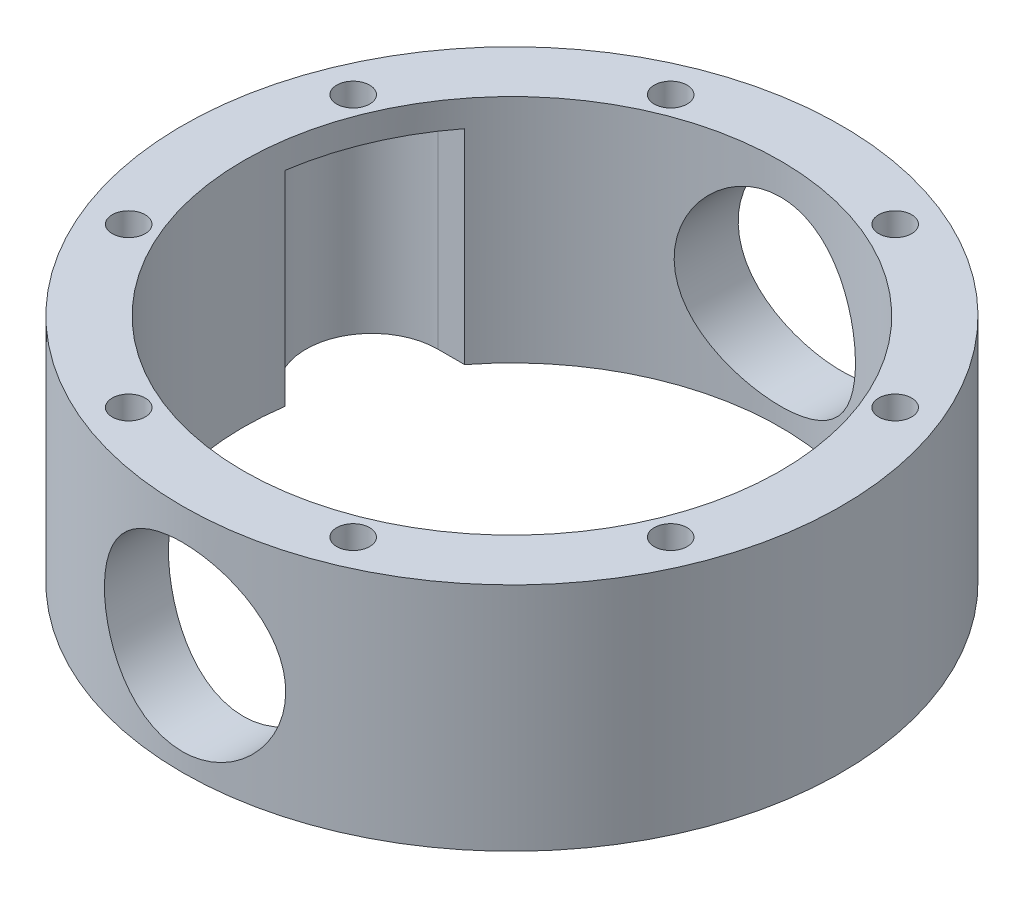
from build123d import *

# Parameters (mm, degrees)
SKETCH1_R               = 100
SKETCH1_R_2             = 81.5
BOSS_EXTRUDE1_DEPTH     = 35
SKETCH3_R               = 27.5
CUT_EXTRUDE1_DEPTH      = 101
CUT_EXTRUDE1_DEPTH_BACK = 101
SKETCH4_R               = 5
CUT_EXTRUDE2_DEPTH      = 70
CIRPATTERN1_COUNT       = 8
CUT_EXTRUDE3_DEPTH      = 62


with BuildPart() as part:
    # Sketch1 → Boss-Extrude1 (new body, symmetric)
    with BuildSketch(Plane(origin=(0, 0, 0), x_dir=(1, 0, 0), z_dir=(0, 1, 0))):
        Circle(SKETCH1_R)
        Circle(SKETCH1_R_2, mode=Mode.SUBTRACT)
    extrude(amount=BOSS_EXTRUDE1_DEPTH, both=True)

    # Sketch3 → Cut-Extrude1 (cut, two sides)
    with BuildSketch(Plane.XY) as cut_extrude1_sk:
        with Locations((0, -2)):
            Circle(SKETCH3_R)
    extrude(amount=CUT_EXTRUDE1_DEPTH, mode=Mode.SUBTRACT)
    extrude(cut_extrude1_sk.sketch, amount=-CUT_EXTRUDE1_DEPTH_BACK, mode=Mode.SUBTRACT)

    # Sketch4 → Cut-Extrude2 (cut)
    with BuildSketch(Plane(origin=(0, 35, 0), x_dir=(1, 0, 0), z_dir=(0, 1, 0))):
        with Locations((-34.05882548, 82.225278394)):
            Circle(SKETCH4_R)
    cut_extrude2 = extrude(amount=-CUT_EXTRUDE2_DEPTH, mode=Mode.SUBTRACT)

    # CirPattern1: Cut-Extrude2 ×8 about axis
    cirpattern1_axis = Axis((0, 0, 0), (0, 1, 0))
    for i in range(1, CIRPATTERN1_COUNT):
        add(cut_extrude2.rotate(cirpattern1_axis, i * 360 / CIRPATTERN1_COUNT), mode=Mode.SUBTRACT)

    # Sketch5 → Cut-Extrude3 (cut)
    with BuildSketch(Plane.XZ.offset(35)):
        with BuildLine():
            Line((-72.5, -10), (72.5, -10))
            ThreePointArc((72.5, -10), (92.5, -30), (72.5, -50))
            Line((72.5, -50), (-72.5, -50))
            ThreePointArc((-72.5, -50), (-92.5, -30), (-72.5, -10))
        make_face()
    extrude(amount=-CUT_EXTRUDE3_DEPTH, mode=Mode.SUBTRACT)


solid = part.part
